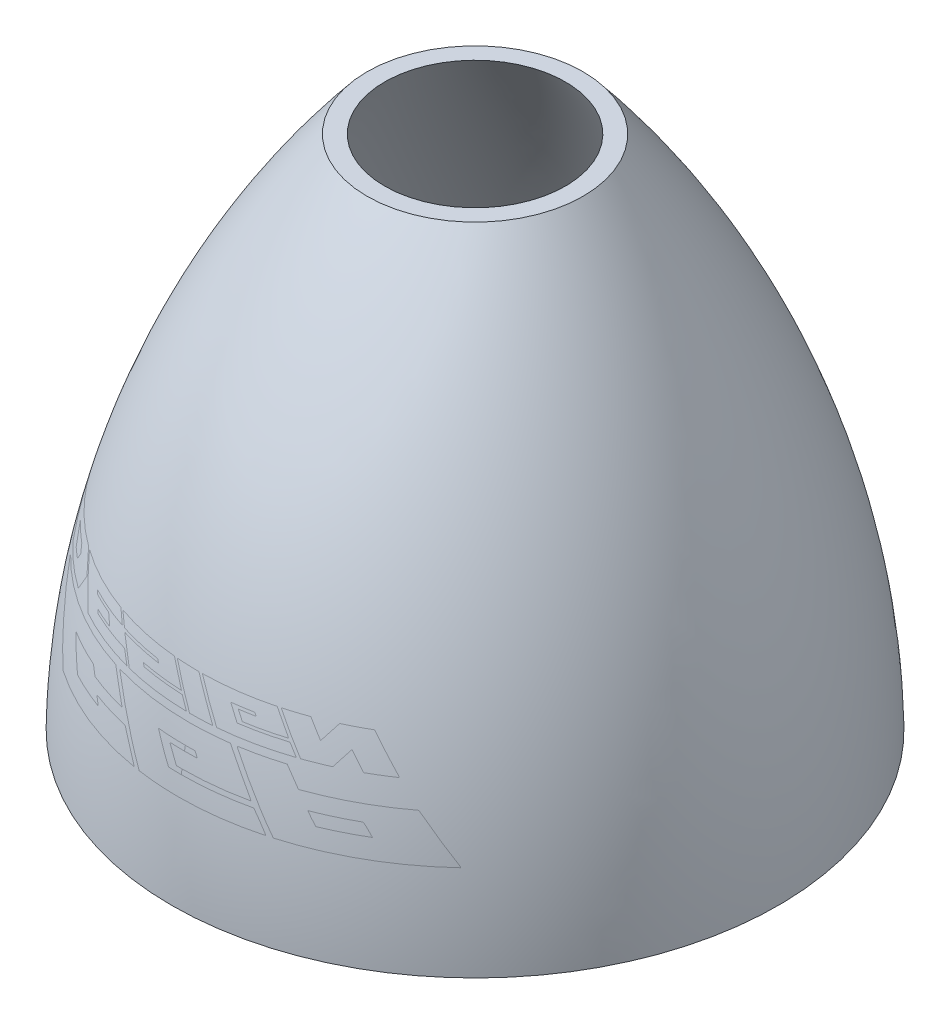
from build123d import *


with BuildPart() as part:
    # Sketch1 → Revolve1 (revolve)
    with BuildSketch(Plane.XY):
        with BuildLine():
            Line((582.911535347, -618.903798344), (630.017345311, -618.903798344))
            add(Edge.make_bspline(
                [(630.017345311, -618.903798344), (623.696176871, -228.954110172), (470.635483281, 152.49619255), (224.250030749, 453.791329838)],
                knots=[0, 0, 0, 0, 1, 1, 1, 1], degree=3))
            Line((224.250030749, 453.791329838), (187.702191418, 453.791329838))
            add(Edge.make_bspline(
                [(582.911535347, -618.903798344), (580.914306618, -428.76419103), (484.954415106, -51.624253025), (302.417257488, 292.529227403), (187.702191418, 453.791329838)],
                knots=[0, 0, 0, 0, 0.48715094, 1, 1, 1, 1], degree=3))
        make_face()
    revolve(axis=Axis((0, 618.903798344, 0), (0, -1, 0)))


solid = part.part
